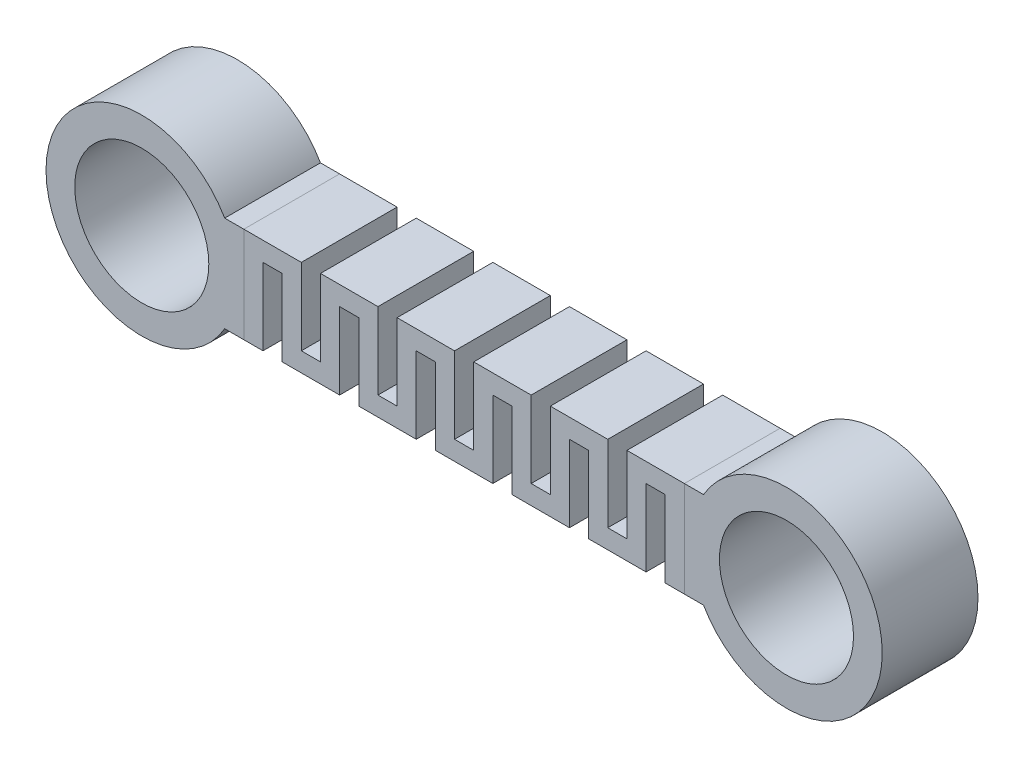
from build123d import *

# Parameters (mm, degrees)
SKETCH1_R             = 7
BOSS_EXTRUDE1_DEPTH   = 10
BOSS_EXTRUDE1_2_DEPTH = 10
BOSS_EXTRUDE2_DEPTH   = 10


with BuildPart() as part:
    # Sketch1 → Boss-Extrude1 (new body)
    with BuildSketch(Plane.XY):
        with BuildLine():
            Line((-23, 5), (-25, 5))
            ThreePointArc((-25, 5), (-43.660254038, 0), (-25, -5))
            Line((-25, -5), (-23, -5))
            Line((-23, -5), (-23, 5))
        make_face()
        with Locations((-33.660254038, 0)):
            Circle(SKETCH1_R, mode=Mode.SUBTRACT)
    extrude(amount=BOSS_EXTRUDE1_DEPTH)


with BuildPart() as body_2:
    # Sketch1 → Boss-Extrude1 2 (new body)
    with BuildSketch(Plane.XY):
        with BuildLine():
            Line((25, 5), (23, 5))
            Line((23, 5), (23, -5))
            Line((23, -5), (25, -5))
            ThreePointArc((25, -5), (43.660254038, 0), (25, 5))
        make_face()
        with Locations((33.660254038, 0)):
            Circle(SKETCH1_R, mode=Mode.SUBTRACT)
    extrude(amount=BOSS_EXTRUDE1_2_DEPTH)


with BuildPart() as body_3:
    # Sketch1_3 → Boss-Extrude2 (new body)
    with BuildSketch(Plane.XY):
        Polygon((-17, 5), (-23, 5), (-23, -5), (-21, -5), (-21, 3), (-19, 3), (-19, -5), (-13, -5), (-13, 3), (-11, 3), (-11, -5), (-5, -5), (-5, 3), (-3, 3), (-3, -5), (3, -5), (3, 3), (5, 3), (5, -5), (11, -5), (11, 3), (13, 3), (13, -5), (19, -5), (19, 3), (21, 3), (21, -5), (23, -5), (23, -3), (23, 5), (17, 5), (17, -3), (15, -3), (15, 5), (9, 5), (9, -3), (7, -3), (7, 5), (1, 5), (1, -3), (-1, -3), (-1, 5), (-7, 5), (-7, -3), (-9, -3), (-9, 5), (-15, 5), (-15, -3), (-17, -3), align=None)
    extrude(amount=BOSS_EXTRUDE2_DEPTH)


solid = Compound([part.part, body_2.part, body_3.part])
